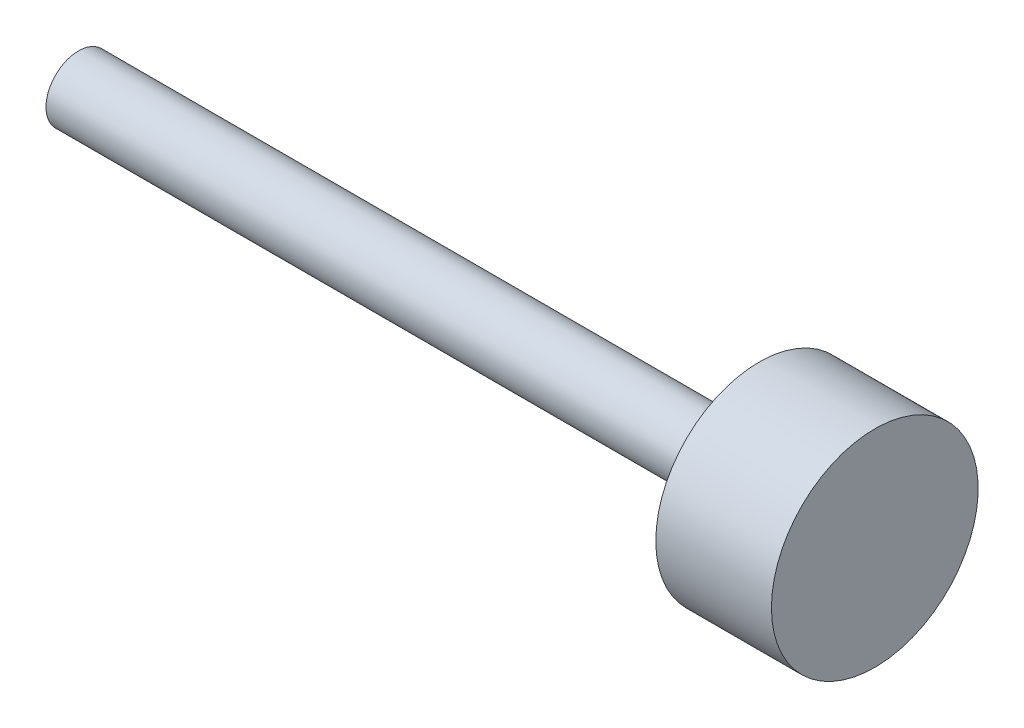
from build123d import *

# Parameters (mm, degrees)
HOLE1_D           = 9.73836
HOLE1_DEPTH       = 28.062477616
HOLE1_CSINK_D     = 11.1125
HOLE1_CSINK_ANGLE = 90
HOLE1_TIP         = 2.811222384


with BuildPart() as part:
    # Sketch1 → Revolve1 (revolve)
    with BuildSketch(Plane.XY):
        Polygon((-22.225, 0), (-22.225, 8.001), (145.3642, 8.001), (145.3642, 25.4508), (173.8376, 25.4508), (173.8376, 0), align=None)
    revolve(axis=Axis((173.8376, 0, 0), (-1, 0, 0)))

    # Hole1
    with Locations(Plane.ZY.offset(22.225)):
        with Locations((0, 0)):
            CounterSinkHole(HOLE1_D / 2, HOLE1_CSINK_D / 2, depth=HOLE1_DEPTH, counter_sink_angle=HOLE1_CSINK_ANGLE)
            with Locations((0, 0, -(HOLE1_DEPTH + HOLE1_TIP / 2))):  # 120° drill point
                Cone(0, HOLE1_D / 2, HOLE1_TIP, mode=Mode.SUBTRACT)


solid = part.part
